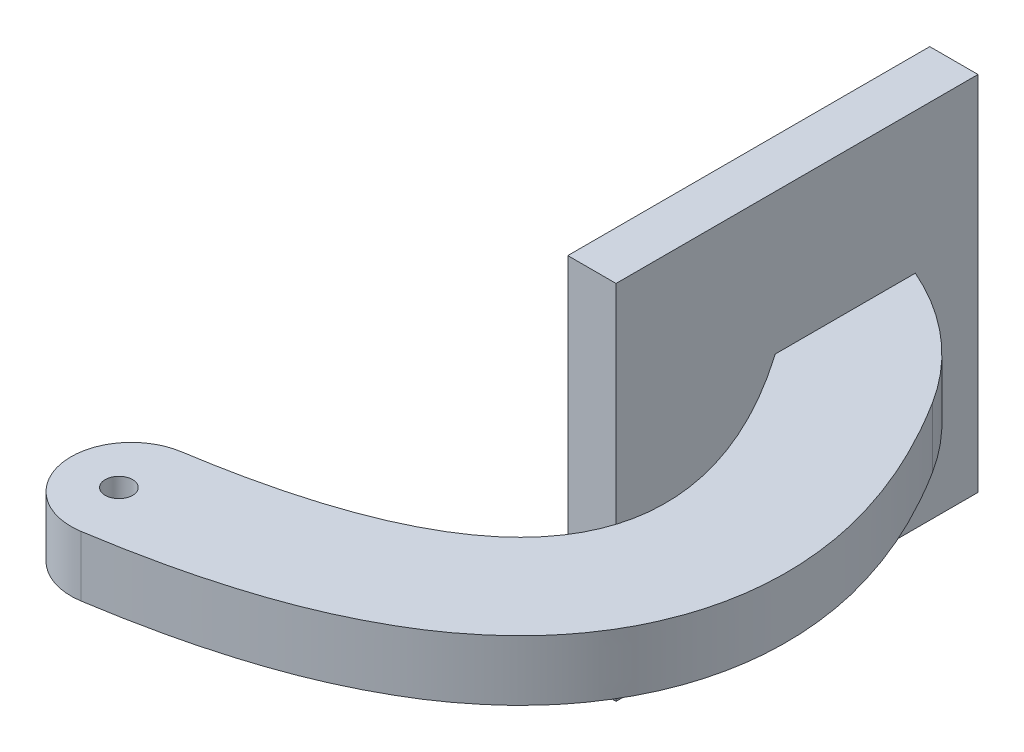
from build123d import *

# Parameters (mm, degrees)
BOSS_EXTRUDE1_DEPTH      = 2.5
BOSS_EXTRUDE1_DEPTH_BACK = 2.5
SKETCH2_W                = 30
SKETCH2_H                = 30
BOSS_EXTRUDE2_DEPTH      = 4
CUT_EXTRUDE1_DEPTH       = 47.112311827
CUT_EXTRUDE1_DEPTH_BACK  = 5
SKETCH3_R                = 1.135899117


with BuildPart() as part:
    # Sketch1 → Boss-Extrude1 (new, two sides: drawn at the far end of the back side and taken through both)
    with BuildSketch(Plane(origin=(0, 0, 0), x_dir=(1, 0, 0), z_dir=(0, 1, 0)).offset(-BOSS_EXTRUDE1_DEPTH_BACK)):
        with BuildLine():
            Line((12.299846055, 27.042802031), (12.299846055, 15.43488972))
            add(Edge.make_bspline(
                [(12.299846055, 15.43488972), (30.534020994, -10.609424361), (-5.28178023, -16.186011799)],
                knots=[0, 0, 0, 1, 1, 1], degree=2))
            ThreePointArc((-5.28178023, -16.186011799), (-9.455741342, -21.893729502), (-3.748023639, -26.067690614))
            add(Edge.make_bspline(
                [(22.317047717, 18.444557689), (24.010987248, 15.756852788), (26.568030042, 10.329200416), (28.199135579, 4.70608307), (28.530980206, -0.219774719), (28.112095037, -4.221352146), (26.937580955, -8.124121484), (25.039004829, -11.720082951), (22.553291074, -14.857561986), (18.908458845, -18.15546642), (13.009520485, -21.610616265), (6.232054982, -23.983751971), (-0.197461384, -25.517985733), (-3.748023639, -26.067690614)],
                knots=[0.045025553, 0.045025553, 0.045025553, 0.134554407, 0.224083261, 0.313612116, 0.373298019, 0.432983922, 0.492669825, 0.552355728, 0.612041631, 0.701570485, 0.820942291, 0.910471146, 1, 1, 1], degree=2))
            ThreePointArc((22.317047717, 18.444557689), (17.956231252, 23.498367255), (12.299846055, 27.042802031))
        make_face()
    extrude(amount=BOSS_EXTRUDE1_DEPTH + BOSS_EXTRUDE1_DEPTH_BACK)

    # Sketch2 → Boss-Extrude2 (add)
    with BuildSketch(Plane.ZY.offset(-12.299846055)):
        with Locations((-17.236867662, -0.834397369)):
            Rectangle(SKETCH2_W, SKETCH2_H)
    extrude(amount=BOSS_EXTRUDE2_DEPTH)

    # Sketch3 → Cut-Extrude1 (cut, two sides: drawn at the far end of the back side and taken through both)
    with BuildSketch(Plane.XZ.offset(2.5).offset(-CUT_EXTRUDE1_DEPTH_BACK)):
        with Locations((-5.323414867, 21.345746187)):
            Circle(SKETCH3_R)
    extrude(amount=CUT_EXTRUDE1_DEPTH + CUT_EXTRUDE1_DEPTH_BACK, mode=Mode.SUBTRACT)


solid = part.part
